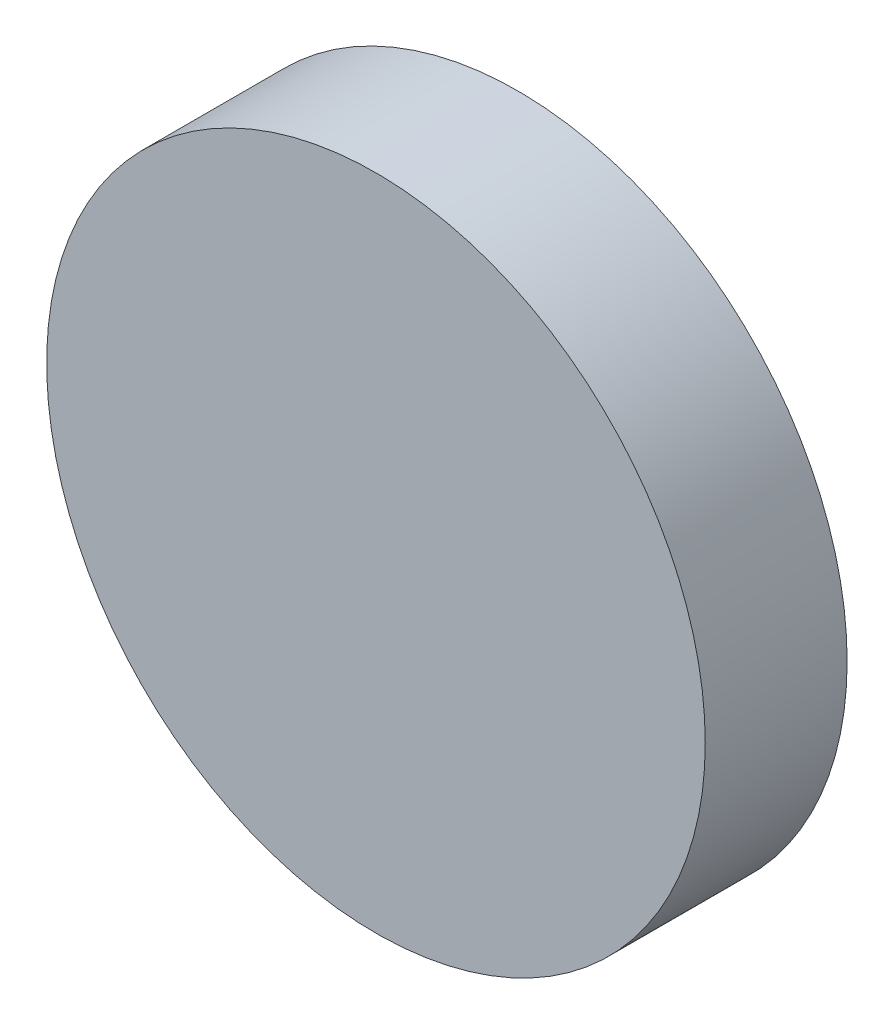
from build123d import *

# Parameters (mm, degrees)
ESQUISSE1_R        = 13.925
BOSS_EXTRU_1_DEPTH = 6


with BuildPart() as part:
    # Esquisse1 → Boss.-Extru.1 (new body)
    with BuildSketch(Plane.XY):
        Circle(ESQUISSE1_R)
    extrude(amount=BOSS_EXTRU_1_DEPTH)


solid = part.part
